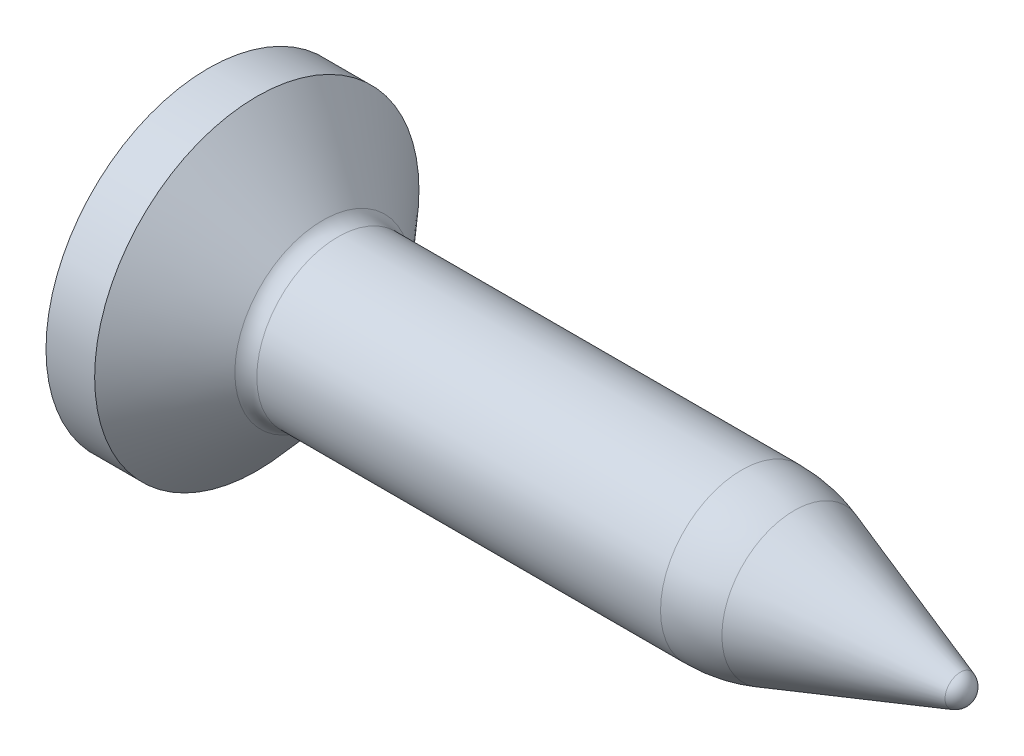
from build123d import *

# Parameters (mm, degrees)
CUT_EXTRUDE1_DEPTH = 0.5


with BuildPart() as part:
    # Sketch1 → Revolve1 (revolve)
    with BuildSketch(Plane.XY):
        with BuildLine():
            Line((0, 0), (0, 2))
            Line((0, 2), (0.6, 2))
            Line((0.6, 2), (1.413030615, 1.084040821))
            ThreePointArc((1.413030615, 1.084040821), (1.497505597, 1.021976103), (1.6, 1))
            Line((1.6, 1), (6.579697282, 1))
            ThreePointArc((6.579697282, 1), (6.908495257, 0.972787848), (7.228345931, 0.891891892))
            Line((7.228345931, 0.891891892), (9.27789548, 0.189189189))
            ThreePointArc((9.27789548, 0.189189189), (9.37577731, 0.116247639), (9.413030615, 0))
            Line((9.413030615, 0), (0, 0))
        make_face()
    revolve(axis=Axis((-3.974685283, 0, 0), (1, 0, 0)))

    # Sketch2 → Cut-Extrude1 (cut)
    with BuildSketch(Plane.ZY):
        Polygon((-0.25, 1), (0.25, 1), (0.362422173, 0.362422173), (1, 0.25), (1, -0.25), (0.362422173, -0.362422173), (0.25, -1), (-0.25, -1), (-0.362422173, -0.362422173), (-1, -0.25), (-1, 0.25), (-0.362422173, 0.362422173), align=None)
    extrude(amount=-CUT_EXTRUDE1_DEPTH, mode=Mode.SUBTRACT)


solid = part.part
